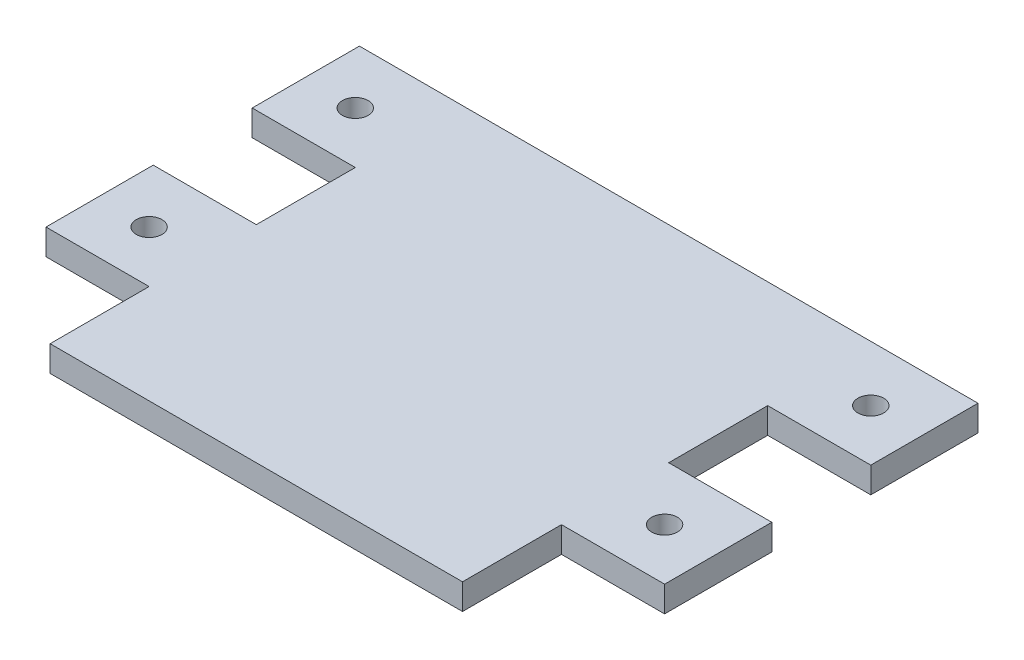
from build123d import *

# Parameters (mm, degrees)
SKETCH1_W               = 50.8
SKETCH1_H               = 50.8
BOSS_EXTRUDE1_DEPTH     = 3.175
SKETCH2_W               = 12.7
SKETCH2_H               = 13.208
SKETCH2_R               = 1.5875
BOSS_EXTRUDE2_DEPTH     = 3.175
LPATTERN1_COUNT         = 2
LPATTERN1_PITCH         = 25.4
MIRROR1_COPY_1_SKETCH_W = 12.7
MIRROR1_COPY_1_SKETCH_H = 13.208
MIRROR1_COPY_1_SKETCH_R = 1.5875
MIRROR1_COPY_1_DEPTH    = 3.175


with BuildPart() as part:
    # Sketch1 → Boss-Extrude1 (new body)
    with BuildSketch(Plane(origin=(0, 0, 0), x_dir=(1, 0, 0), z_dir=(0, 1, 0))):
        with Locations((25.4, 25.4)):
            Rectangle(SKETCH1_W, SKETCH1_H)
    extrude(amount=BOSS_EXTRUDE1_DEPTH)

    # Sketch2 → Boss-Extrude2 (add)
    with BuildSketch(Plane(origin=(0, 3.175, 0), x_dir=(1, 0, 0), z_dir=(0, 1, 0))):
        with Locations((57.15, 44.196)):
            Rectangle(SKETCH2_W, SKETCH2_H)
        with Locations((57.15, 43.942)):
            Circle(SKETCH2_R, mode=Mode.SUBTRACT)
    boss_extrude2 = extrude(amount=-BOSS_EXTRUDE2_DEPTH)

    # LPattern1: Boss-Extrude2 ×2
    with Locations(*[(0, 0, i * LPATTERN1_PITCH) for i in range(1, LPATTERN1_COUNT)]):
        add(boss_extrude2)

    # Mirror1: Boss-Extrude2 across plane
    add(boss_extrude2.mirror(Plane.ZY.offset(-25.4)))

    # Mirror1 copy 1 sketch → Mirror1 copy 1 (add)
    with BuildSketch(Plane(origin=(50.8, 3.175, 25.4), x_dir=(-1, 0, 0), z_dir=(0, 1, 0))):
        with Locations((57.15, -44.196)):
            Rectangle(MIRROR1_COPY_1_SKETCH_W, MIRROR1_COPY_1_SKETCH_H)
        with Locations((57.15, -43.942)):
            Circle(MIRROR1_COPY_1_SKETCH_R, mode=Mode.SUBTRACT)
    extrude(amount=-MIRROR1_COPY_1_DEPTH)


solid = part.part
